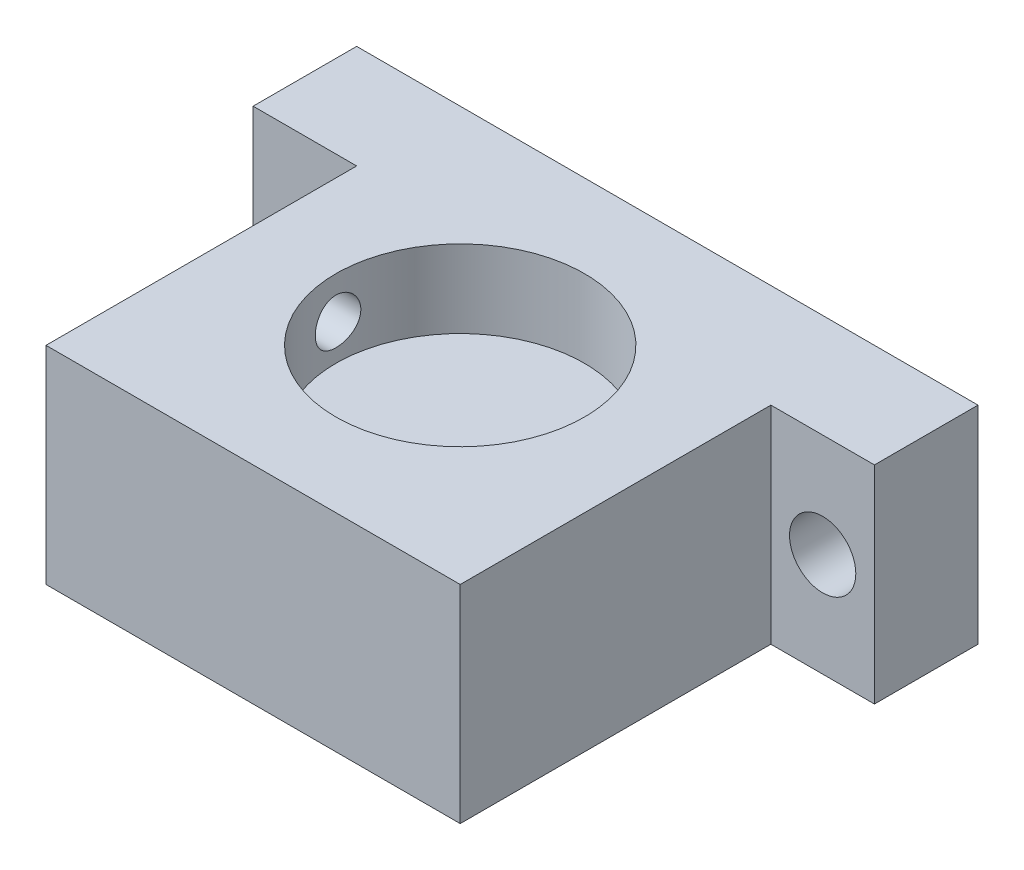
from build123d import *

# Parameters (mm, degrees)
SKETCH1_W           = 20
SKETCH1_H           = 20
BOSS_EXTRUDE1_DEPTH = 10
SKETCH2_R           = 6
CUT_EXTRUDE1_DEPTH  = 3.75
CUT_EXTRUDE3_REACH  = 22
SKETCH5_R           = 1.1
SKETCH6_W           = 5
SKETCH6_H           = 10
BOSS_EXTRUDE2_DEPTH = 5
SKETCH7_R           = 1.6
CUT_EXTRUDE4_DEPTH  = 6


with BuildPart() as part:
    # Sketch1 → Boss-Extrude1 (new body)
    with BuildSketch(Plane(origin=(0, 0, 0), x_dir=(1, 0, 0), z_dir=(0, 1, 0))):
        with Locations((10, 10)):
            Rectangle(SKETCH1_W, SKETCH1_H)
    extrude(amount=BOSS_EXTRUDE1_DEPTH)

    # Sketch2 → Cut-Extrude1 (cut)
    with BuildSketch(Plane(origin=(0, 10, 0), x_dir=(1, 0, 0), z_dir=(0, 1, 0))):
        with Locations((10, 10)):
            Circle(SKETCH2_R)
    extrude(amount=-CUT_EXTRUDE1_DEPTH, mode=Mode.SUBTRACT)

    # Sketch5 → Cut-Extrude3 (cut, up to next)
    with BuildSketch(Plane.ZY, mode=Mode.PRIVATE) as cut_extrude3_sk1:
        with Locations((-10, 8)):
            Circle(SKETCH5_R)
    cut_extrude3_tool1 = extrude(cut_extrude3_sk1.sketch, amount=-CUT_EXTRUDE3_REACH, mode=Mode.PRIVATE) & part.part
    add(cut_extrude3_tool1.solids().sort_by_distance((0, 8, -10))[0], mode=Mode.SUBTRACT)

    # Sketch6 → Boss-Extrude2 (add)
    with BuildSketch(Plane(origin=(20, 0, 0), x_dir=(0, 0, -1), z_dir=(1, 0, 0))):
        with Locations((17.5, 5)):
            Rectangle(SKETCH6_W, SKETCH6_H)
    boss_extrude2 = extrude(amount=BOSS_EXTRUDE2_DEPTH)

    # Sketch7 → Cut-Extrude4 (cut, through all)
    with BuildSketch(Plane.XY.offset(-15)):
        with Locations((22.5, 5)):
            Circle(SKETCH7_R)
    cut_extrude4 = extrude(amount=-CUT_EXTRUDE4_DEPTH, mode=Mode.SUBTRACT)

    # Mirror1: Boss-Extrude2, Cut-Extrude4 across plane
    add(boss_extrude2.mirror(Plane.ZY.offset(-10)))
    add(cut_extrude4.mirror(Plane.ZY.offset(-10)), mode=Mode.SUBTRACT)


solid = part.part
